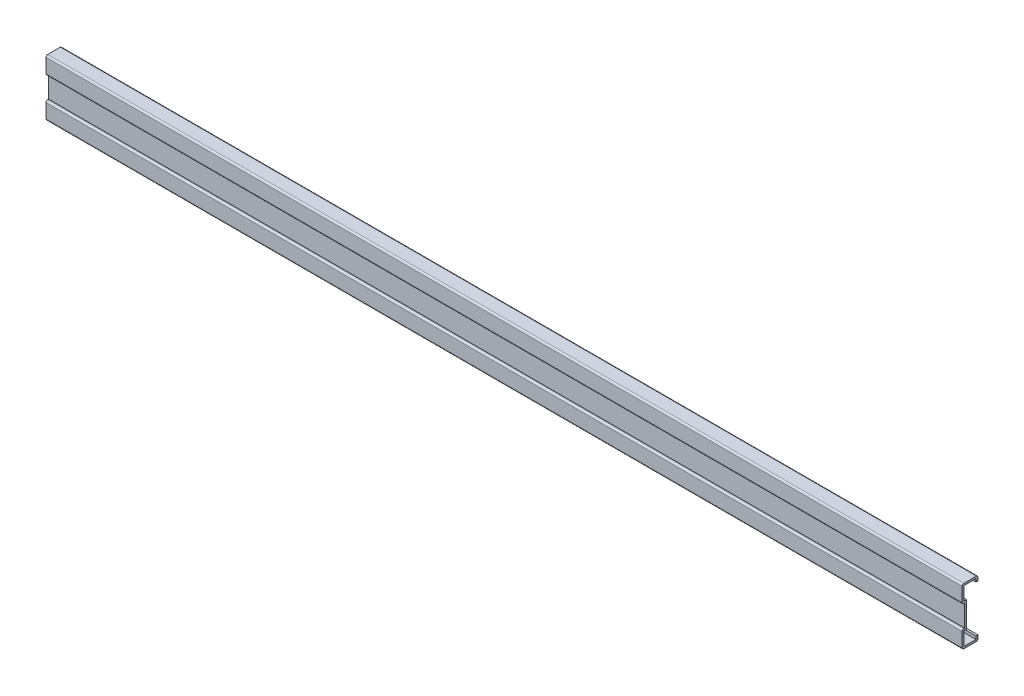
from build123d import *

# Parameters (mm, degrees)
EXTRUDE_3_DEPTH = 550


with BuildPart() as part:
    # Эскиз1 → Вытянуть-Тонкостенный3 (new body)
    with BuildSketch(Plane(origin=(0, 0, 0), x_dir=(0, 0, -1), z_dir=(1, 0, 0))):
        with BuildLine():
            Line((8, 14), (8, 16))
            ThreePointArc((8, 16), (7.707106781, 16.707106781), (7, 17))
            Line((7, 17), (-0.5, 17))
            ThreePointArc((-0.5, 17), (-1.207106781, 16.707106781), (-1.5, 16))
            Line((-1.5, 16), (-1.5, 7.5))
            ThreePointArc((-1.5, 7.5), (-1.207106781, 6.792893219), (-0.5, 6.5))
            Line((-0.5, 6.5), (0, 6.5))
            Line((0, 6.5), (0, -6.5))
            Line((0, -6.5), (-0.5, -6.5))
            ThreePointArc((-0.5, -6.5), (-1.207106781, -6.792893219), (-1.5, -7.5))
            Line((-1.5, -7.5), (-1.5, -16))
            ThreePointArc((-1.5, -16), (-1.207106781, -16.707106781), (-0.5, -17))
            Line((-0.5, -17), (7, -17))
            ThreePointArc((7, -17), (7.707106781, -16.707106781), (8, -16))
            Line((8, -16), (8, -14))
            Line((8, -14), (6.8, -14))
            Line((6.8, -14), (6.8, -15.8))
            Line((6.8, -15.8), (-0.3, -15.8))
            Line((-0.3, -15.8), (-0.3, -7.7))
            Line((-0.3, -7.7), (1.2, -7.7))
            Line((1.2, -7.7), (1.2, 7.7))
            Line((1.2, 7.7), (-0.3, 7.7))
            Line((-0.3, 7.7), (-0.3, 15.8))
            Line((-0.3, 15.8), (6.8, 15.8))
            Line((6.8, 15.8), (6.8, 14))
            Line((6.8, 14), (8, 14))
        make_face()
    extrude(amount=EXTRUDE_3_DEPTH)


solid = part.part
